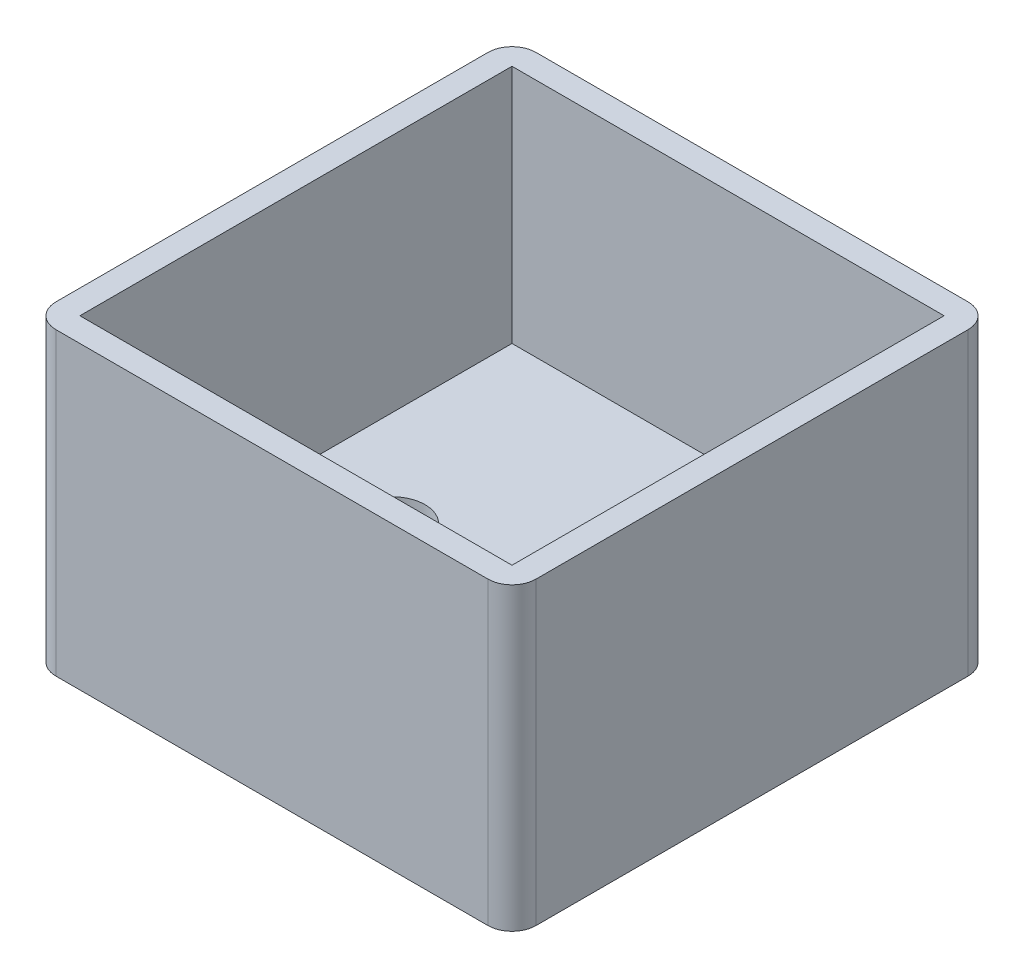
from build123d import *

# Parameters (mm, degrees)
SKETCH1_R           = 2.75
BASE_DEPTH          = 5
SKETCH3_W           = 36
SKETCH3_H           = 36
BOSS_EXTRUDE2_DEPTH = 20


with BuildPart() as part:
    # Sketch1 → base (new body)
    with BuildSketch(Plane(origin=(0, 0, 0), x_dir=(1, 0, 0), z_dir=(0, 1, 0))):
        with BuildLine():
            Line((2, 0), (38, 0))
            ThreePointArc((38, 0), (39.414213562, 0.585786438), (40, 2))
            Line((40, 2), (40, 38))
            ThreePointArc((40, 38), (39.414213562, 39.414213562), (38, 40))
            Line((38, 40), (2, 40))
            ThreePointArc((2, 40), (0.585786438, 39.414213562), (0, 38))
            Line((0, 38), (0, 2))
            ThreePointArc((0, 2), (0.585786438, 0.585786438), (2, 0))
        make_face()
        with Locations((10, 20)):
            Circle(SKETCH1_R, mode=Mode.SUBTRACT)
        with Locations((30, 20)):
            Circle(SKETCH1_R, mode=Mode.SUBTRACT)
    extrude(amount=BASE_DEPTH)

    # Sketch3 → Boss-Extrude2 (add)
    with BuildSketch(Plane(origin=(0, 5, 0), x_dir=(1, 0, 0), z_dir=(0, 1, 0))):
        with BuildLine():
            Line((0, 38), (0, 2))
            ThreePointArc((0, 2), (0.585786438, 0.585786438), (2, 0))
            Line((2, 0), (38, 0))
            ThreePointArc((38, 0), (39.414213562, 0.585786438), (40, 2))
            Line((40, 2), (40, 38))
            ThreePointArc((40, 38), (39.414213562, 39.414213562), (38, 40))
            Line((38, 40), (2, 40))
            ThreePointArc((2, 40), (0.585786438, 39.414213562), (0, 38))
        make_face()
        with Locations((20, 20)):
            Rectangle(SKETCH3_W, SKETCH3_H, mode=Mode.SUBTRACT)
    extrude(amount=BOSS_EXTRUDE2_DEPTH)


solid = part.part
